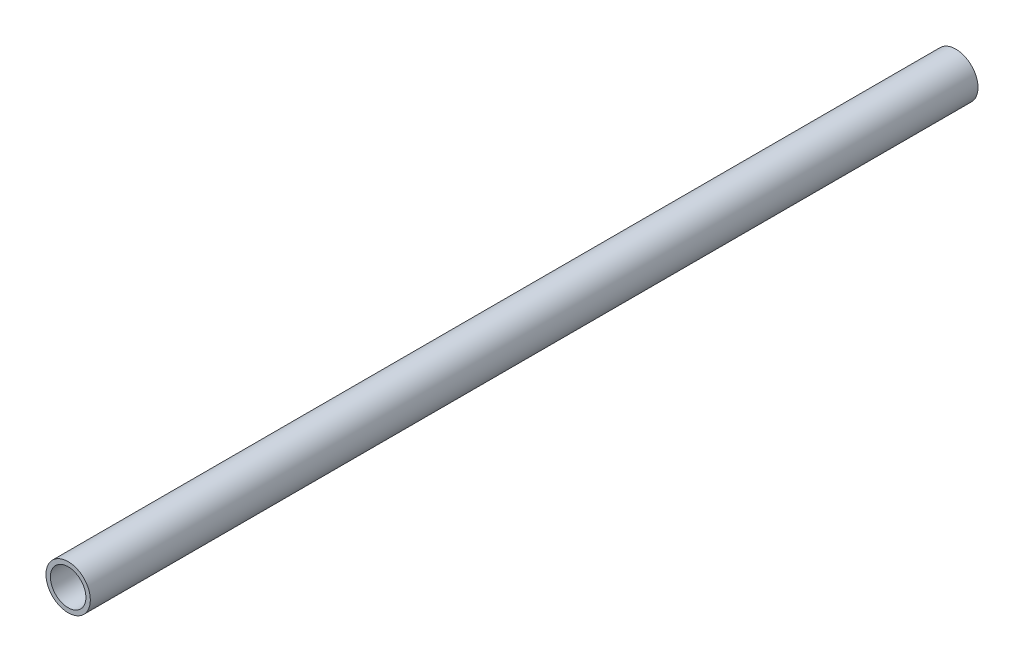
from build123d import *

# Parameters (mm, degrees)
SKETCH1_R           = 5
SKETCH1_R_2         = 4
BOSS_EXTRUDE1_DEPTH = 200


with BuildPart() as part:
    # Sketch1 → Boss-Extrude1 (new body)
    with BuildSketch(Plane.XY):
        Circle(SKETCH1_R)
        Circle(SKETCH1_R_2, mode=Mode.SUBTRACT)
    extrude(amount=BOSS_EXTRUDE1_DEPTH)


solid = part.part
